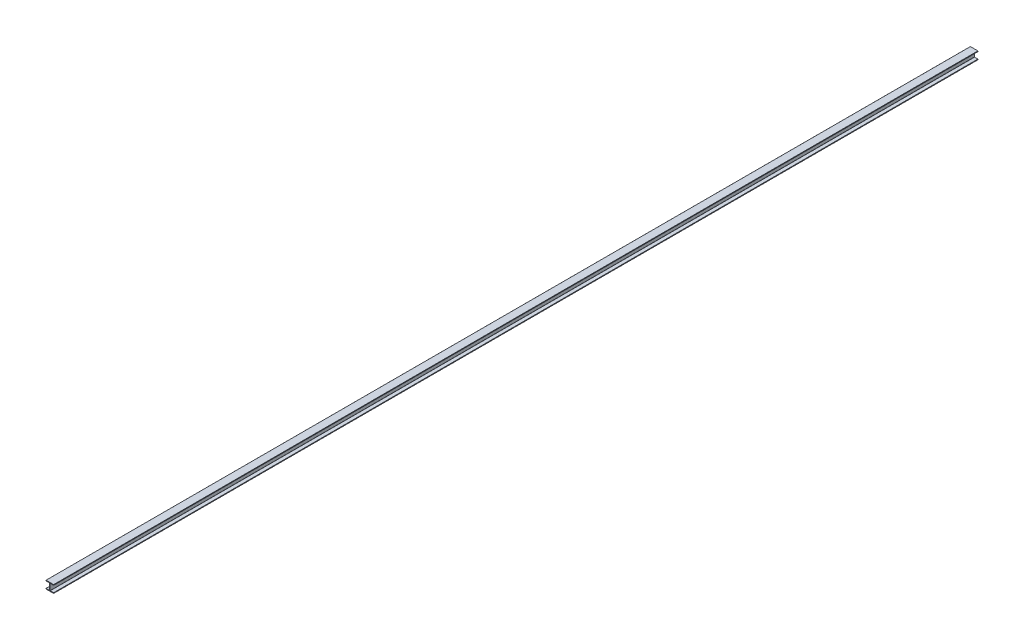
from build123d import *

# Parameters (mm, degrees)
RAIL_DEPTH = 7620


with BuildPart() as part:
    # Rail Cross Section → Rail (new body, symmetric)
    with BuildSketch(Plane.XY):
        with BuildLine():
            Line((-63.5, -61.976), (-63.5, -54.5592))
            ThreePointArc((-63.5, -54.5592), (-63.053630735, -53.481569265), (-61.976, -53.0352))
            Line((-61.976, -53.0352), (-6.7691, -53.0352))
            ThreePointArc((-6.7691, -53.0352), (-5.691469265, -52.588830735), (-5.2451, -51.5112))
            Line((-5.2451, -51.5112), (-5.2451, 51.5112))
            ThreePointArc((-5.2451, 51.5112), (-5.691469265, 52.588830735), (-6.7691, 53.0352))
            Line((-6.7691, 53.0352), (-61.976, 53.0352))
            ThreePointArc((-61.976, 53.0352), (-63.053630735, 53.481569265), (-63.5, 54.5592))
            Line((-63.5, 54.5592), (-63.5, 61.976))
            ThreePointArc((-63.5, 61.976), (-63.053630735, 63.053630735), (-61.976, 63.5))
            Line((-61.976, 63.5), (61.976, 63.5))
            ThreePointArc((61.976, 63.5), (63.053630735, 63.053630735), (63.5, 61.976))
            Line((63.5, 61.976), (63.5, 54.5592))
            ThreePointArc((63.5, 54.5592), (63.053630735, 53.481569265), (61.976, 53.0352))
            Line((61.976, 53.0352), (6.7691, 53.0352))
            ThreePointArc((6.7691, 53.0352), (5.691469265, 52.588830735), (5.2451, 51.5112))
            Line((5.2451, 51.5112), (5.2451, -51.5112))
            ThreePointArc((5.2451, -51.5112), (5.691469265, -52.588830735), (6.7691, -53.0352))
            Line((6.7691, -53.0352), (61.976, -53.0352))
            ThreePointArc((61.976, -53.0352), (63.053630735, -53.481569265), (63.5, -54.5592))
            Line((63.5, -54.5592), (63.5, -61.976))
            ThreePointArc((63.5, -61.976), (63.053630735, -63.053630735), (61.976, -63.5))
            Line((61.976, -63.5), (-61.976, -63.5))
            ThreePointArc((-61.976, -63.5), (-63.053630735, -63.053630735), (-63.5, -61.976))
        make_face()
    extrude(amount=RAIL_DEPTH, both=True)


solid = part.part
